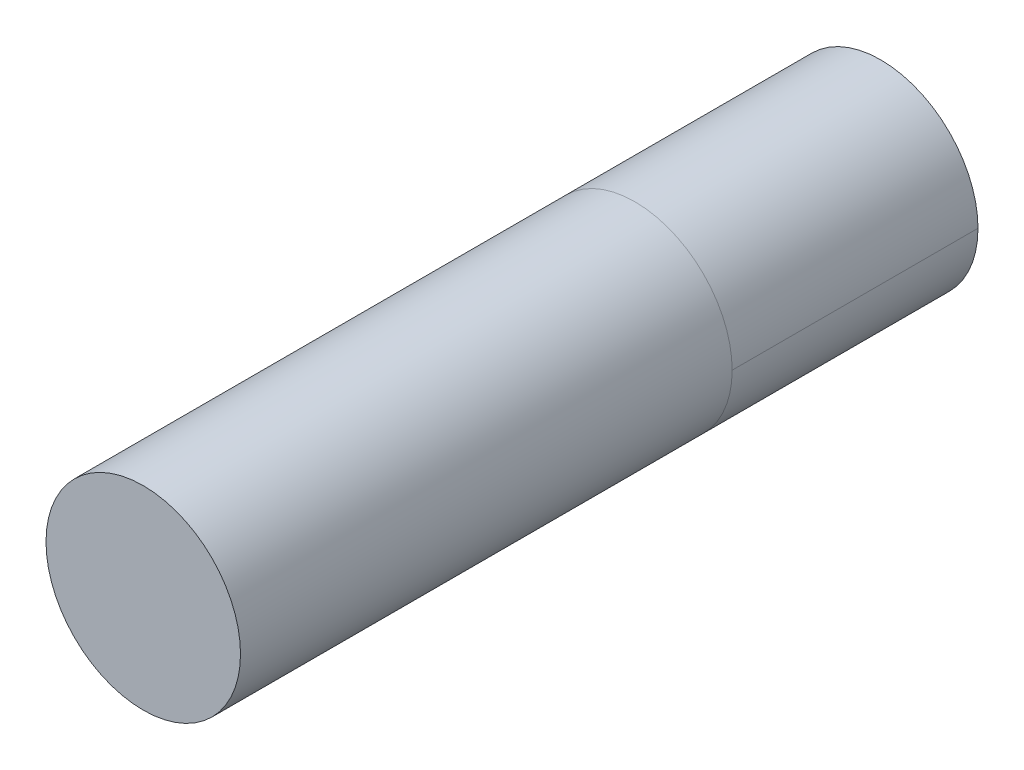
from build123d import *

# Parameters (mm, degrees)
SKETCH1_R           = 1.25603
BOSS_EXTRUDE1_DEPTH = 3.175
SKETCH3_R           = 1.25603
BOSS_EXTRUDE2_DEPTH = 6.35


with BuildPart() as part:
    # Sketch1 → Boss-Extrude1 (new body)
    with BuildSketch(Plane.XY):
        Circle(SKETCH1_R)
    extrude(amount=BOSS_EXTRUDE1_DEPTH)


with BuildPart() as body_2:
    # Sketch3 → Boss-Extrude2 (new body)
    with BuildSketch(Plane.XY.offset(3.175)):
        Circle(SKETCH3_R)
    extrude(amount=BOSS_EXTRUDE2_DEPTH)


solid = Compound([part.part, body_2.part])
